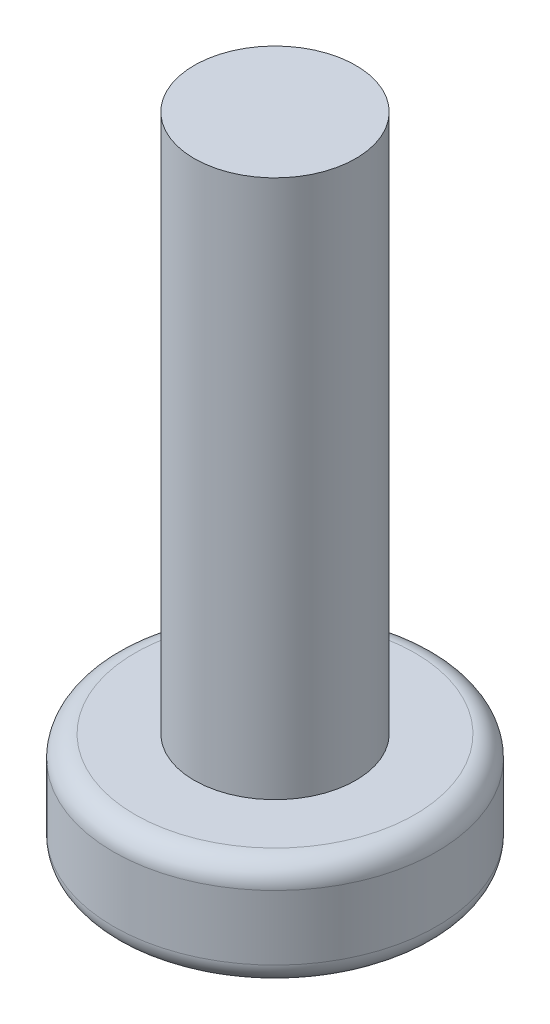
from build123d import *

# Parameters (mm, degrees)
SKETCH1_R           = 3
BOSS_EXTRUDE1_DEPTH = 2
SKETCH2_R           = 1.5
BOSS_EXTRUDE2_DEPTH = 10
SKETCH3_W           = 0.9
SKETCH3_H           = 0.9
SKETCH3_W_2         = 1.05
SKETCH3_H_2         = 1.05
CUT_EXTRUDE1_DEPTH  = 1.9
FILLET1_R           = 0.4


with BuildPart() as part:
    # Sketch1 → Boss-Extrude1 (new body)
    with BuildSketch(Plane(origin=(0, 0, 0), x_dir=(1, 0, 0), z_dir=(0, 1, 0))):
        Circle(SKETCH1_R)
    extrude(amount=BOSS_EXTRUDE1_DEPTH)

    # Sketch2 → Boss-Extrude2 (add)
    with BuildSketch(Plane(origin=(0, 2, 0), x_dir=(1, 0, 0), z_dir=(0, 1, 0))):
        Circle(SKETCH2_R)
    extrude(amount=BOSS_EXTRUDE2_DEPTH)

    # Sketch3 → Cut-Extrude1 (cut)
    with BuildSketch(Plane(origin=(0, 0, 0), x_dir=(-1, 0, 0), z_dir=(0, -1, 0))):
        Rectangle(SKETCH3_W, SKETCH3_H)
        with Locations((0.975, 0)):
            Rectangle(SKETCH3_W_2, SKETCH3_H)
        with Locations((0, -0.975)):
            Rectangle(SKETCH3_W, SKETCH3_H_2)
        with Locations((-0.975, 0)):
            Rectangle(SKETCH3_W_2, SKETCH3_H)
        with Locations((0, 0.975)):
            Rectangle(SKETCH3_W, SKETCH3_H_2)
    extrude(amount=-CUT_EXTRUDE1_DEPTH, mode=Mode.SUBTRACT)

    # Fillet1
    fillet1_edges = [part.edges().sort_by_distance(p)[0] for p in [
        (-3, 0, 0),
        (-3, 2, 0),
    ]]
    fillet(fillet1_edges, radius=FILLET1_R)


solid = part.part
